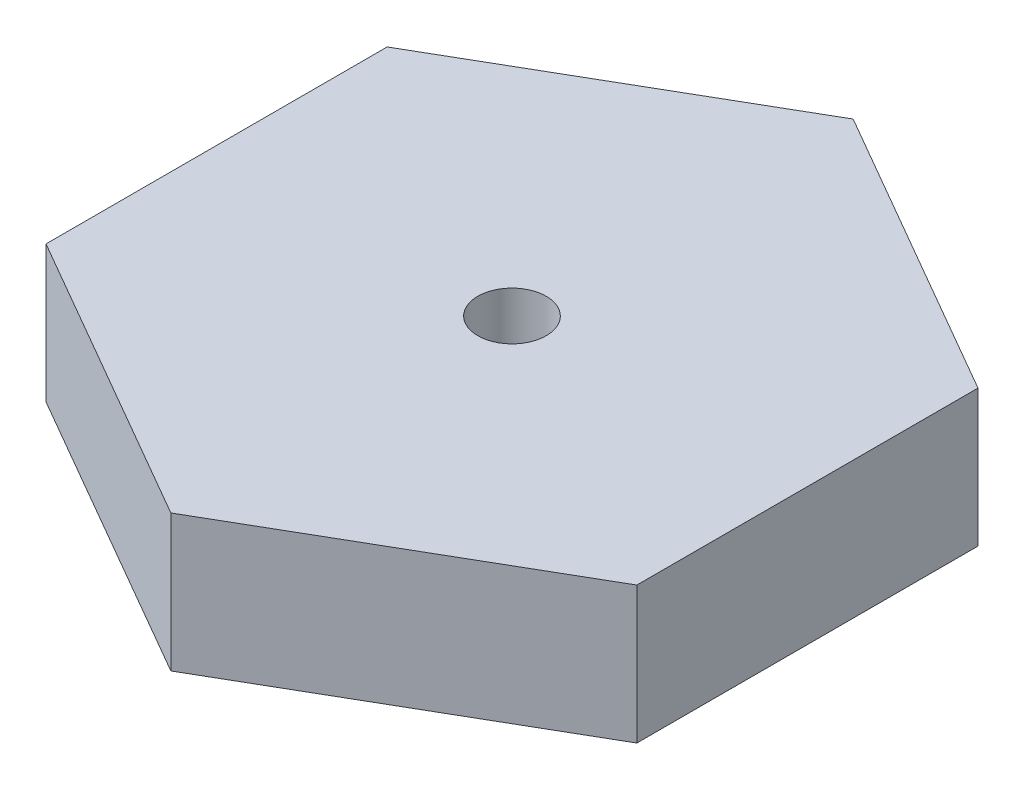
from build123d import *

# Parameters (mm, degrees)
SKETCH1_R           = 1.27
BOSS_EXTRUDE4_DEPTH = 5.08


with BuildPart() as part:
    # Sketch1 → Boss-Extrude4 (new body)
    with BuildSketch(Plane(origin=(0, 0, 0), x_dir=(1, 0, 0), z_dir=(0, 1, 0))):
        Polygon((0, 12.662852008), (-10.966351523, 6.331426004), (-10.966351523, -6.331426004), (0, -12.662852008), (10.966351523, -6.331426004), (10.966351523, 6.331426004), align=None)
        Circle(SKETCH1_R, mode=Mode.SUBTRACT)
    extrude(amount=BOSS_EXTRUDE4_DEPTH)


solid = part.part
